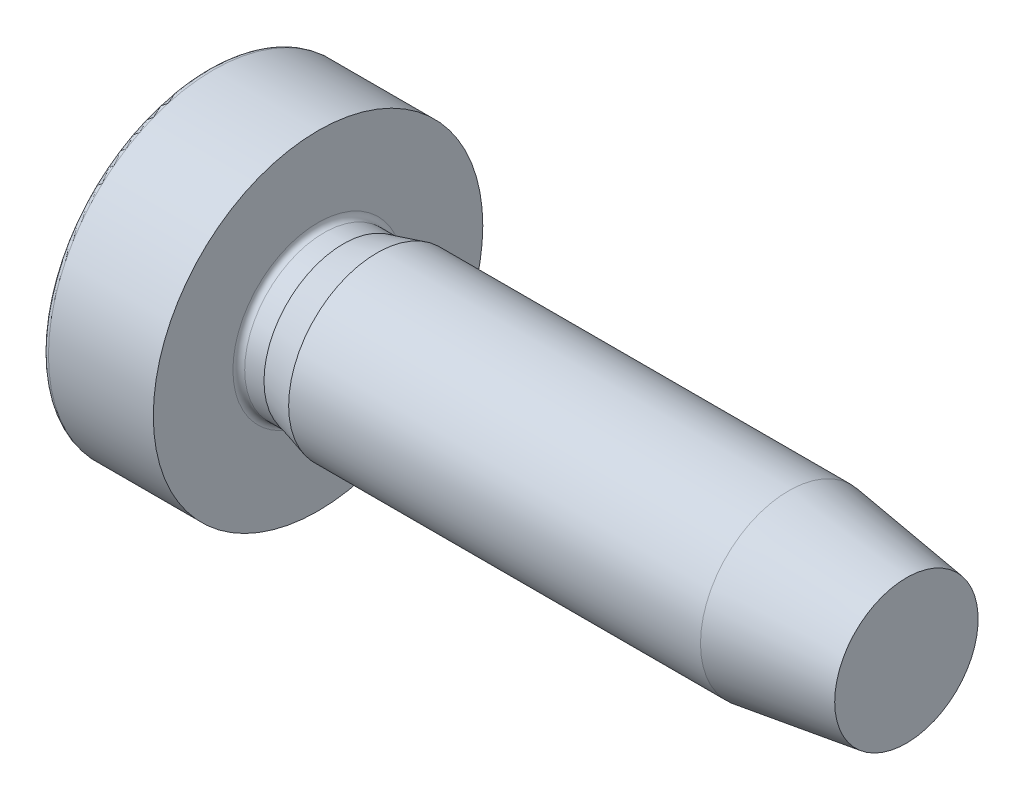
from build123d import *

# Parameters (mm, degrees)
CUT_EXTRUDE1_DEPTH      = 1.2
CUT_EXTRUDE1_DEPTH_BACK = 1.2


with BuildPart() as part:
    # Sketch1 → Revolve1 (revolve)
    with BuildSketch(Plane.XY):
        with BuildLine():
            Line((-1.782329983, 2.8), (0, 2.8))
            Line((0, 2.8), (0, 1.44675))
            ThreePointArc((0, 1.44675), (0.029289322, 1.376039322), (0.1, 1.34675))
            Line((0.1, 1.34675), (0.428063214, 1.34675))
            Line((0.428063214, 1.34675), (1, 1.5))
            Line((1, 1.5), (8, 1.5))
            Line((8, 1.5), (10, 1.218918331))
            Line((10, 1.218918331), (10, 0))
            Line((10, 0), (-2.4, 0))
            ThreePointArc((-2.4, 0), (-2.267625669, 1.393419223), (-1.875238613, 2.736986301))
            ThreePointArc((-1.875238613, 2.736986301), (-1.838460945, 2.782760589), (-1.782329983, 2.8))
        make_face()
    revolve(axis=Axis((13, 0, 0), (-1, 0, 0)))

    # Sketch2 → Cut-Extrude1 (cut, two sides)
    with BuildSketch(Plane(origin=(-2.4, 0, 0), x_dir=(0, 0, -1), z_dir=(1, 0, 0))) as cut_extrude1_sk:
        Polygon((-1.5, 0.375), (-1.5, -0.375), (-0.6, -0.296260203), (-0.375, -0.375), (-0.296260203, -0.6), (-0.375, -1.5), (0.375, -1.5), (0.296260203, -0.6), (0.375, -0.375), (0.6, -0.296260203), (1.5, -0.375), (1.5, 0.375), (0.6, 0.296260203), (0.375, 0.375), (0.296260203, 0.6), (0.375, 1.5), (-0.375, 1.5), (-0.296260203, 0.6), (-0.375, 0.375), (-0.6, 0.296260203), align=None)
    extrude(amount=CUT_EXTRUDE1_DEPTH, mode=Mode.SUBTRACT)
    extrude(cut_extrude1_sk.sketch, amount=-CUT_EXTRUDE1_DEPTH_BACK, mode=Mode.SUBTRACT)


solid = part.part
